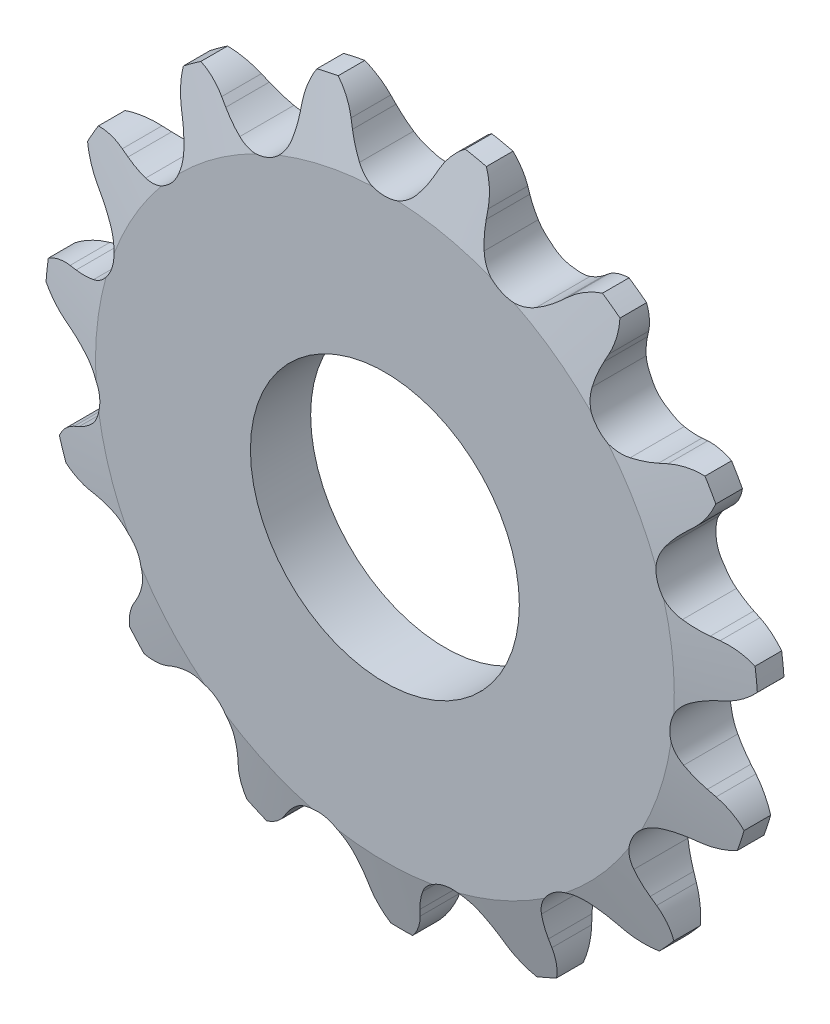
from build123d import *

# Parameters (mm, degrees)
CUT_EXTRUDE1_DEPTH      = 36.791353611
CIRPATTERN1_COUNT       = 15
CUT_EXTRUDE2_DEPTH      = 36.742160228
CUT_EXTRUDE2_DEPTH_BACK = 36.742160228
SKETCH3_OUTSIDE_W       = 66.628
SKETCH3_OUTSIDE_H       = 66.362
SKETCH3_OUTSIDE_R       = 25.273
SKETCH3_OUTSIDE_R_2     = 6.35
SKETCH4_R               = 9.525
CUT_EXTRUDE3_DEPTH      = 36.932697715


with BuildPart() as part:
    # Sketch1 → Revolve1 (revolve)
    with BuildSketch(Plane(origin=(0, 0, 0), x_dir=(0, 0, -1), z_dir=(1, 0, 0)), mode=Mode.PRIVATE) as revolve1_sk:
        Polygon((2.1336, 0), (-2.1336, 0), (-2.1336, 20.500800896), (-0.942975, 25.263300896), (0.942975, 25.263300896), (2.1336, 20.500800896), align=None)
    revolve(revolve1_sk.sketch.rotate(Axis((0, 0, -2.1336), (0, 0, 1)), 90), axis=Axis((0, 0, -2.1336), (0, 0, 1)))

    # Sketch0 → Cut-Extrude1 (cut, symmetric)
    with BuildSketch(Plane.XY):
        with BuildLine():
            Line((7.876845215, -22.037606674), (7.538283816, -21.58394277))
            ThreePointArc((7.538283816, -21.58394277), (7.002749236, -20.952462067), (6.392943269, -20.392371139))
            ThreePointArc((6.392943269, -20.392371139), (4.223842391, -19.871616092), (2.454080297, -21.22960231))
            ThreePointArc((2.454080297, -21.22960231), (2.12480433, -21.989301265), (1.892415488, -22.784009129))
            Line((1.892415488, -22.784009129), (1.767645993, -23.336157055))
            ThreePointArc((1.767645993, -23.336157055), (0.110022884, -25.836136287), (-2.78970089, -26.603738115))
            ThreePointArc((-2.78970089, -26.603738115), (5.561555391, -26.165060947), (13.36923371, -23.169050536))
            ThreePointArc((13.36923371, -23.169050536), (10.407992437, -23.647235287), (7.876845215, -22.037606674))
        make_face()
    cut_extrude1 = extrude(amount=CUT_EXTRUDE1_DEPTH, both=True, mode=Mode.SUBTRACT)

    # CirPattern1: Cut-Extrude1 ×15 about axis
    cirpattern1_axis = Axis((0, 0, 0), (0, 0, 1))
    for i in range(1, CIRPATTERN1_COUNT):
        add(cut_extrude1.rotate(cirpattern1_axis, i * 360 / CIRPATTERN1_COUNT), mode=Mode.SUBTRACT)

    # Sketch3 outside → Cut-Extrude2 (cut, two sides: drawn at the far end of the back side and taken through both)
    # profile 1 of 2: a face of its own
    with BuildSketch(Plane.XY.offset(-CUT_EXTRUDE2_DEPTH_BACK)):
        with Locations((0, -0.202)):
            Rectangle(SKETCH3_OUTSIDE_W, SKETCH3_OUTSIDE_H)
        Circle(SKETCH3_OUTSIDE_R, mode=Mode.SUBTRACT)
    # profile 2 of 2: a face of its own
    with BuildSketch(Plane.XY.offset(-CUT_EXTRUDE2_DEPTH_BACK)):
        Circle(SKETCH3_OUTSIDE_R_2)
    extrude(amount=CUT_EXTRUDE2_DEPTH + CUT_EXTRUDE2_DEPTH_BACK, mode=Mode.SUBTRACT)

    # Sketch4 → Cut-Extrude3 (cut, through all)
    with BuildSketch(Plane.XY.offset(2.1336)):
        Circle(SKETCH4_R)
    extrude(amount=-CUT_EXTRUDE3_DEPTH, mode=Mode.SUBTRACT)


solid = part.part
